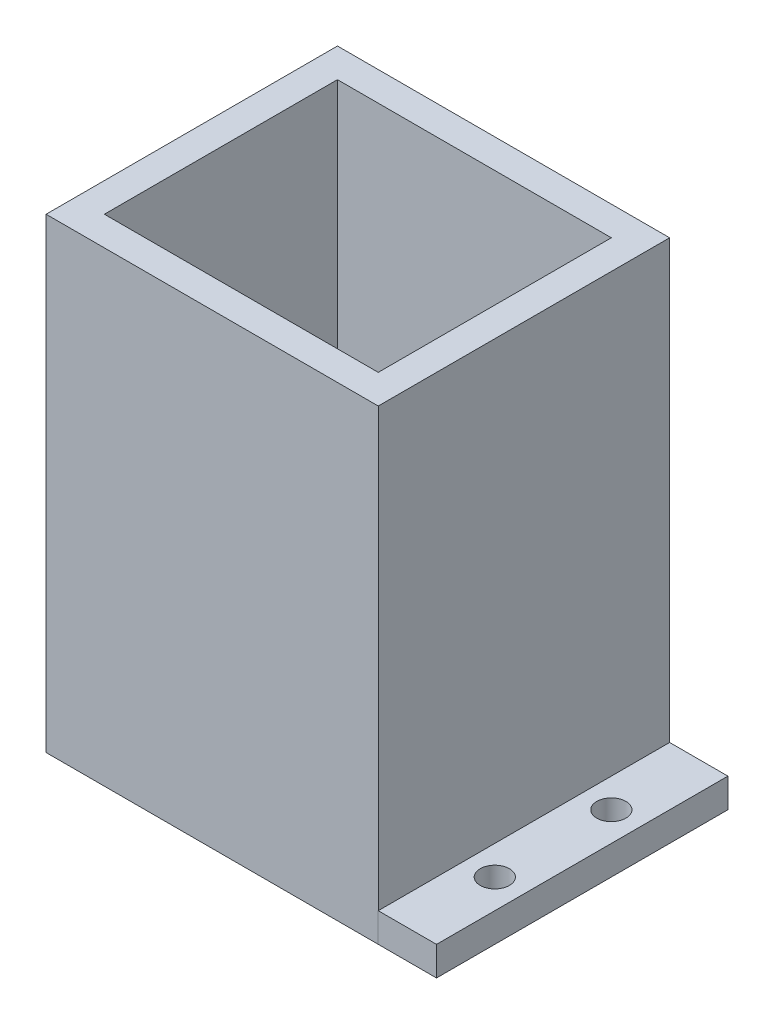
from build123d import *

# Parameters (mm, degrees)
SKETCH1_W           = 57
SKETCH1_H           = 50
BOSS_EXTRUDE1_DEPTH = 80
SKETCH2_W           = 47
SKETCH2_H           = 40
CUT_EXTRUDE1_DEPTH  = 75
SKETCH3_W           = 10
SKETCH3_H           = 50.004105979
SKETCH3_R           = 2.5
BOSS_EXTRUDE2_DEPTH = 5


with BuildPart() as part:
    # Sketch1 → Boss-Extrude1 (new body)
    with BuildSketch(Plane(origin=(0, 0, 0), x_dir=(1, 0, 0), z_dir=(0, 1, 0))):
        with Locations((25.218232044, -22.546961326)):
            Rectangle(SKETCH1_W, SKETCH1_H)
    extrude(amount=BOSS_EXTRUDE1_DEPTH)

    # Sketch2 → Cut-Extrude1 (cut)
    with BuildSketch(Plane(origin=(0, 80, 0), x_dir=(1, 0, 0), z_dir=(0, 1, 0))):
        with Locations((25.218232044, -22.546961326)):
            Rectangle(SKETCH2_W, SKETCH2_H)
    extrude(amount=-CUT_EXTRUDE1_DEPTH, mode=Mode.SUBTRACT)

    # Sketch3 → Boss-Extrude2 (add)
    with BuildSketch(Plane(origin=(0, 0, 0), x_dir=(1, 0, 0), z_dir=(0, 1, 0))):
        with Locations((58.718232044, -22.549014316)):
            Rectangle(SKETCH3_W, SKETCH3_H)
        with Locations((58.718232044, -12.551067305)):
            Circle(SKETCH3_R, mode=Mode.SUBTRACT)
        with Locations((58.718232044, -32.551067305)):
            Circle(SKETCH3_R, mode=Mode.SUBTRACT)
    extrude(amount=BOSS_EXTRUDE2_DEPTH)


solid = part.part
